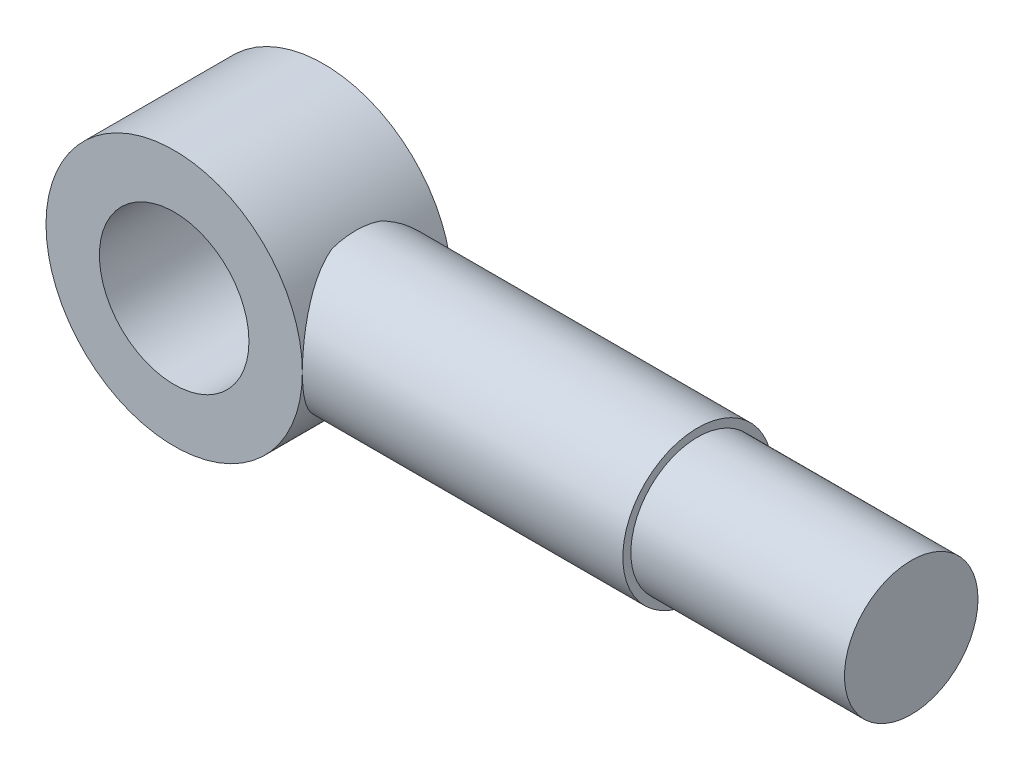
from build123d import *

# Parameters (mm, degrees)
SKETCH1_R           = 24
SKETCH1_R_2         = 14
BOSS_EXTRUDE3_DEPTH = 14
BOSS_EXTRUDE7_START = 20
SKETCH5_R           = 14
BOSS_EXTRUDE7_DEPTH = 64
SKETCH7_R           = 12.5
BOSS_EXTRUDE8_DEPTH = 40


with BuildPart() as part:
    # Sketch1 → Boss-Extrude3 (new body, symmetric)
    with BuildSketch(Plane.XY):
        Circle(SKETCH1_R)
        Circle(SKETCH1_R_2, mode=Mode.SUBTRACT)
    extrude(amount=BOSS_EXTRUDE3_DEPTH, both=True)

    # Sketch5 → Boss-Extrude7 (add)
    with BuildSketch(Plane(origin=(0, 0, 0), x_dir=(0, 0, -1), z_dir=(1, 0, 0)).offset(BOSS_EXTRUDE7_START)):
        Circle(SKETCH5_R)
    extrude(amount=BOSS_EXTRUDE7_DEPTH)

    # Sketch7 → Boss-Extrude8 (add)
    with BuildSketch(Plane(origin=(84, 0, 0), x_dir=(0, 0, -1), z_dir=(1, 0, 0))):
        Circle(SKETCH7_R)
    extrude(amount=BOSS_EXTRUDE8_DEPTH)


solid = part.part
